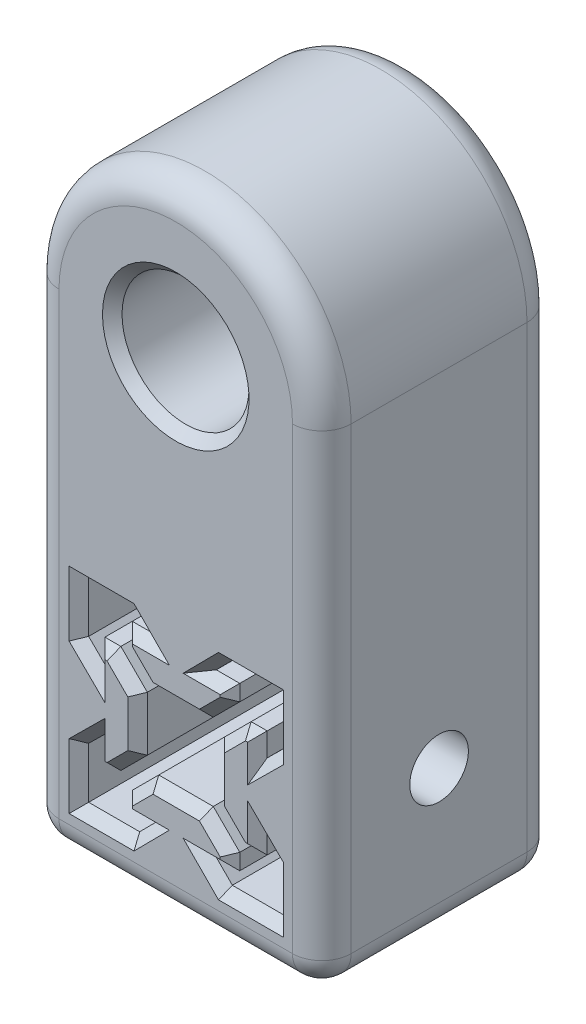
from build123d import *

# Parameters (mm, degrees)
BOSS_EXTRUDE1_DEPTH = 24
SKETCH4_R           = 6.5
BOSS_EXTRUDE2_DEPTH = 24
SKETCH3_R           = 3
CUT_EXTRUDE1_DEPTH  = 30.899298428
FILLET1_R           = 3
CHAMFER1_SIZE       = 1


with BuildPart() as part:
    # Sketch1 → Boss-Extrude1 (new body)
    with BuildSketch(Plane.XY):
        Polygon((0, 15), (14.899298428, 15), (14.899298428, -14.949649214), (-15, -14.949649214), (-15, 15), align=None)
        Polygon((-9.966432809, 9.966432809), (-4.741432809, 9.966432809), (-3.1, 8.307461143), (-5.5, 8.307461143), (-5.5, 6.667461143), (-2.79, 3.957461143), (2.79, 3.957461143), (5.5, 6.667461143), (5.5, 8.307461143), (3.1, 8.307461143), (4.741432809, 9.966432809), (9.966432809, 9.966432809), (9.966432809, 4.741432809), (8.307461143, 3.1), (8.307461143, 5.5), (6.667461143, 5.5), (3.957461143, 2.79), (3.957461143, -2.79), (6.667461143, -5.5), (8.307461143, -5.5), (8.307461143, -3.1), (9.966432809, -4.741432809), (9.966432809, -9.966432809), (4.741432809, -9.966432809), (3.1, -8.307461143), (5.5, -8.307461143), (5.5, -6.667461143), (2.79, -3.957461143), (-2.79, -3.957461143), (-5.5, -6.667461143), (-5.5, -8.307461143), (-3.1, -8.307461143), (-4.741432809, -9.966432809), (-9.966432809, -9.966432809), (-9.966432809, -4.741432809), (-8.307461143, -3.1), (-8.307461143, -5.5), (-6.667461143, -5.5), (-3.957461143, -2.79), (-3.957461143, 2.79), (-6.667461143, 5.5), (-8.307461143, 5.5), (-8.307461143, 3.1), (-9.966432809, 4.741432809), align=None, mode=Mode.SUBTRACT)
    extrude(amount=BOSS_EXTRUDE1_DEPTH)

    # Sketch4 → Boss-Extrude2 (add)
    with BuildSketch(Plane(origin=(0, 0, 0), x_dir=(-1, 0, 0), z_dir=(0, 0, -1))):
        with BuildLine():
            ThreePointArc((-14.899298428, 35), (0.050350786, 49.949649214), (15, 35))
            Line((15, 35), (15, 15))
            Line((15, 15), (-14.899298428, 15))
            Line((-14.899298428, 15), (-14.899298428, 35))
        make_face()
        with Locations((0.050350786, 35)):
            Circle(SKETCH4_R, mode=Mode.SUBTRACT)
    extrude(amount=-BOSS_EXTRUDE2_DEPTH)

    # Sketch3 → Cut-Extrude1 (cut, through all)
    with BuildSketch(Plane.ZY.offset(15)):
        with Locations((12, 0)):
            Circle(SKETCH3_R)
    extrude(amount=-CUT_EXTRUDE1_DEPTH, mode=Mode.SUBTRACT)

    # Fillet1
    fillet1_edges = [part.edges().sort_by_distance(p)[0] for p in [
        (-0.050350786, -14.949649214, 24),
        (14.899298428, 10.025175393, 24),
        (-0.050350786, 49.949649214, 24),
        (-0.050350786, 49.949649214, 0),
        (14.899298428, 10.025175393, 0),
        (-0.050350786, -14.949649214, 0),
        (-15, 10.025175393, 0),
        (-15, 10.025175393, 24),
        (14.899298428, -14.949649214, 12),
        (-15, -14.949649214, 12),
    ]]
    fillet(fillet1_edges, radius=FILLET1_R)

    # Chamfer1
    chamfer1_edges = [part.edges().sort_by_distance(p)[0] for p in [
        (6.449649214, 35, 24),
        (6.449649214, 35, 0),
        (-4.3, 8.307461143, 0),
        (-3.920716405, 9.136946976, 0),
        (-7.353932809, 9.966432809, 0),
        (-9.966432809, 7.353932809, 0),
        (-9.136946976, 3.920716405, 0),
        (-8.307461143, 4.3, 0),
        (-7.487461143, 5.5, 0),
        (-5.312461143, 4.145, 0),
        (-3.957461143, 0, 0),
        (-5.312461143, -4.145, 0),
        (-7.487461143, -5.5, 0),
        (-8.307461143, -4.3, 0),
        (-9.136946976, -3.920716405, 0),
        (-9.966432809, -7.353932809, 0),
        (-7.353932809, -9.966432809, 0),
        (-3.920716405, -9.136946976, 0),
        (-4.3, -8.307461143, 0),
        (-5.5, -7.487461143, 0),
        (-4.145, -5.312461143, 0),
        (0, -3.957461143, 0),
        (4.145, -5.312461143, 0),
        (5.5, -7.487461143, 0),
        (4.3, -8.307461143, 0),
        (3.920716405, -9.136946976, 0),
        (7.353932809, -9.966432809, 0),
        (9.966432809, -7.353932809, 0),
        (9.136946976, -3.920716405, 0),
        (8.307461143, -4.3, 0),
        (7.487461143, -5.5, 0),
        (5.312461143, -4.145, 0),
        (3.957461143, 0, 0),
        (5.312461143, 4.145, 0),
        (7.487461143, 5.5, 0),
        (8.307461143, 4.3, 0),
        (9.136946976, 3.920716405, 0),
        (9.966432809, 7.353932809, 0),
        (7.353932809, 9.966432809, 0),
        (3.920716405, 9.136946976, 0),
        (4.3, 8.307461143, 0),
        (5.5, 7.487461143, 0),
        (4.145, 5.312461143, 0),
        (0, 3.957461143, 0),
        (-4.145, 5.312461143, 0),
        (-5.5, 7.487461143, 0),
        (-4.3, 8.307461143, 24),
        (-3.920716405, 9.136946976, 24),
        (-7.353932809, 9.966432809, 24),
        (-9.966432809, 7.353932809, 24),
        (-9.136946976, 3.920716405, 24),
        (-8.307461143, 4.3, 24),
        (-7.487461143, 5.5, 24),
        (-5.312461143, 4.145, 24),
        (-3.957461143, 0, 24),
        (-5.312461143, -4.145, 24),
        (-7.487461143, -5.5, 24),
        (-8.307461143, -4.3, 24),
        (-9.136946976, -3.920716405, 24),
        (-9.966432809, -7.353932809, 24),
        (-7.353932809, -9.966432809, 24),
        (-3.920716405, -9.136946976, 24),
        (-4.3, -8.307461143, 24),
        (-5.5, -7.487461143, 24),
        (-4.145, -5.312461143, 24),
        (0, -3.957461143, 24),
        (4.145, -5.312461143, 24),
        (5.5, -7.487461143, 24),
        (4.3, -8.307461143, 24),
        (3.920716405, -9.136946976, 24),
        (7.353932809, -9.966432809, 24),
        (9.966432809, -7.353932809, 24),
        (9.136946976, -3.920716405, 24),
        (8.307461143, -4.3, 24),
        (7.487461143, -5.5, 24),
        (5.312461143, -4.145, 24),
        (3.957461143, 0, 24),
        (5.312461143, 4.145, 24),
        (7.487461143, 5.5, 24),
        (8.307461143, 4.3, 24),
        (9.136946976, 3.920716405, 24),
        (9.966432809, 7.353932809, 24),
        (7.353932809, 9.966432809, 24),
        (3.920716405, 9.136946976, 24),
        (4.3, 8.307461143, 24),
        (5.5, 7.487461143, 24),
        (4.145, 5.312461143, 24),
        (0, 3.957461143, 24),
        (-4.145, 5.312461143, 24),
        (-5.5, 7.487461143, 24),
    ]]
    chamfer(chamfer1_edges, length=CHAMFER1_SIZE)


solid = part.part
